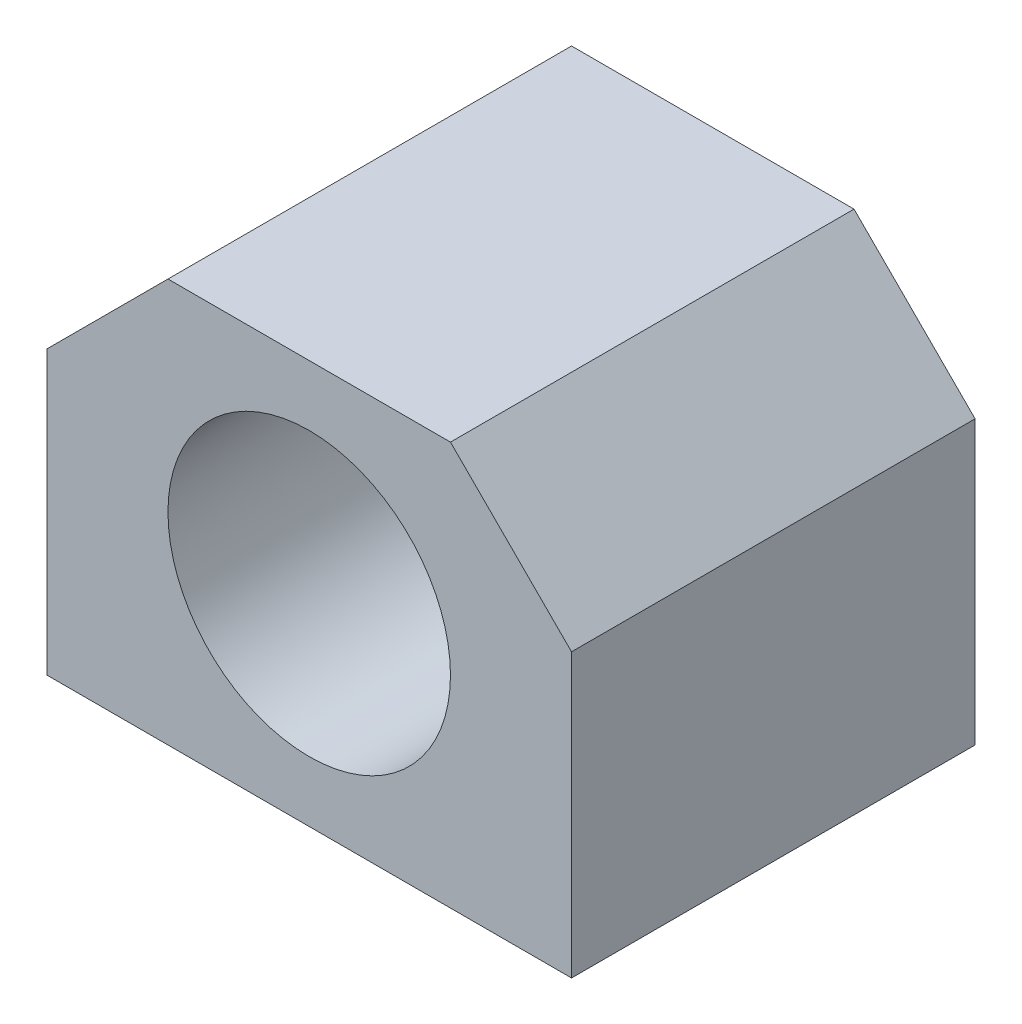
from build123d import *

# Parameters (mm, degrees)
SKETCH1_R           = 14
BOSS_EXTRUDE1_DEPTH = 40
SKETCH2_R           = 2.1
CUT_EXTRUDE1_DEPTH  = 10


with BuildPart() as part:
    # Sketch1 → Boss-Extrude1 (new body)
    with BuildSketch(Plane.XY):
        Polygon((-14, 20), (14, 20), (26, 8), (26, -20), (-26, -20), (-26, 8), align=None)
        Circle(SKETCH1_R, mode=Mode.SUBTRACT)
    extrude(amount=BOSS_EXTRUDE1_DEPTH)

    # Sketch2 → Cut-Extrude1 (cut)
    with BuildSketch(Plane.XZ.offset(20)):
        with Locations((-20, 32)):
            Circle(SKETCH2_R)
        with Locations((20, 32)):
            Circle(SKETCH2_R)
        with Locations((20, 8)):
            Circle(SKETCH2_R)
        with Locations((-20, 8)):
            Circle(SKETCH2_R)
    extrude(amount=-CUT_EXTRUDE1_DEPTH, mode=Mode.SUBTRACT)


solid = part.part
